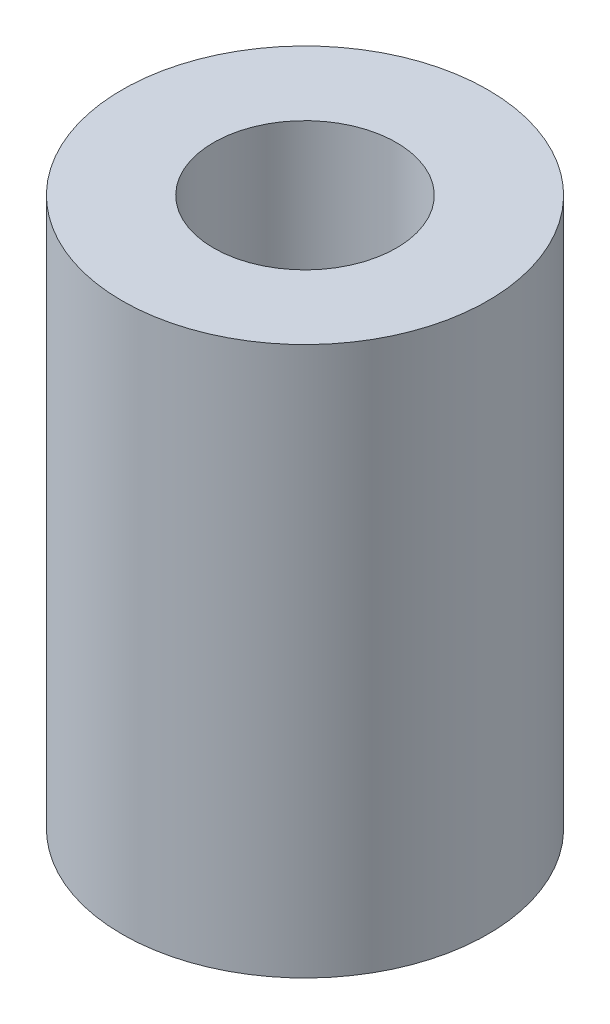
from build123d import *

# Parameters (mm, degrees)
CROQUIS1_R              = 3
SALIENTE_EXTRUIR1_DEPTH = 9
CROQUIS2_R              = 1.5
CORTAR_EXTRUIR1_DEPTH   = 9


with BuildPart() as part:
    # Croquis1 → Saliente-Extruir1 (new body)
    with BuildSketch(Plane(origin=(0, 0, 0), x_dir=(1, 0, 0), z_dir=(0, 1, 0))):
        Circle(CROQUIS1_R)
    extrude(amount=SALIENTE_EXTRUIR1_DEPTH)

    # Croquis2 → Cortar-Extruir1 (cut)
    with BuildSketch(Plane(origin=(0, 9, 0), x_dir=(1, 0, 0), z_dir=(0, 1, 0))):
        Circle(CROQUIS2_R)
    extrude(amount=-CORTAR_EXTRUIR1_DEPTH, mode=Mode.SUBTRACT)


solid = part.part
